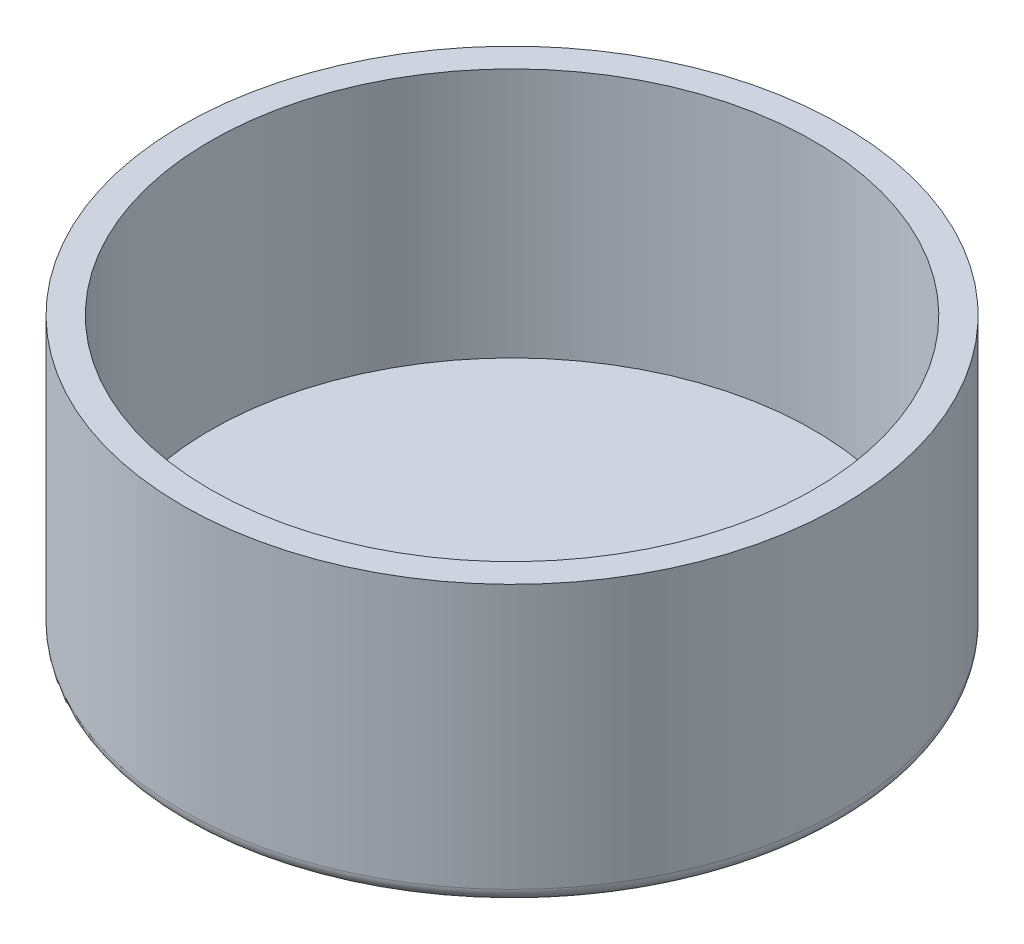
from build123d import *

# Parameters (mm, degrees)
SKETCH1_R           = 11.85
BOSS_EXTRUDE1_DEPTH = 1
SKETCH2_R           = 11.85
SKETCH2_R_2         = 10.85
BOSS_EXTRUDE2_DEPTH = 9
FILLET1_R           = 0.5


with BuildPart() as part:
    # Sketch1 → Boss-Extrude1 (new body)
    with BuildSketch(Plane(origin=(0, 0, 0), x_dir=(1, 0, 0), z_dir=(0, 1, 0))):
        Circle(SKETCH1_R)
    extrude(amount=BOSS_EXTRUDE1_DEPTH)

    # Sketch2 → Boss-Extrude2 (add)
    with BuildSketch(Plane(origin=(0, 1, 0), x_dir=(1, 0, 0), z_dir=(0, 1, 0))):
        Circle(SKETCH2_R)
        Circle(SKETCH2_R_2, mode=Mode.SUBTRACT)
    extrude(amount=BOSS_EXTRUDE2_DEPTH)

    # Fillet1
    fillet1_edges = [part.edges().sort_by_distance(p)[0] for p in [
        (-11.85, 0, 0),
    ]]
    fillet(fillet1_edges, radius=FILLET1_R)


solid = part.part
